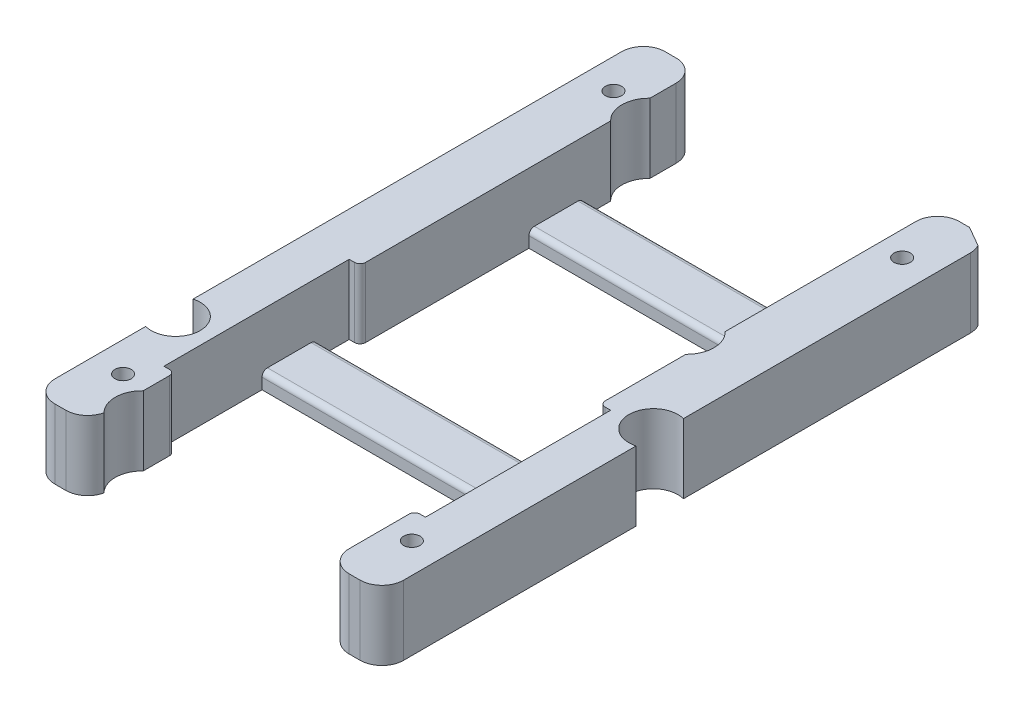
from build123d import *

# Parameters (mm, degrees)
SKETCH1_W             = 10
SKETCH1_H             = 112
BOSS_EXTRUDE1_DEPTH   = 12.75
BOSS_EXTRUDE1_2_DEPTH = 12.75
FILLET1_R             = 4
FILLET2_R             = 4
SKETCH2_R             = 1.5
SKETCH2_R_2           = 3
CUT_EXTRUDE1_DEPTH    = 13.75
SKETCH3_W             = 48
SKETCH3_H             = 34
CUT_EXTRUDE2_DEPTH    = 12.75
SKETCH4_R             = 5
SKETCH4_R_2           = 4.5
CUT_EXTRUDE3_DEPTH    = 13.75
SKETCH5_W             = 10
SKETCH5_H             = 3
BOSS_EXTRUDE2_DEPTH   = 44
BOSS_EXTRUDE3_REACH   = 58
SKETCH6_W             = 10
SKETCH6_H             = 3
FILLET3_R             = 1


with BuildPart() as part:
    # Sketch1 → Boss-Extrude1 (new body)
    with BuildSketch(Plane(origin=(0, 0, 0), x_dir=(1, 0, 0), z_dir=(0, 1, 0))):
        with Locations((-27, 56)):
            Rectangle(SKETCH1_W, SKETCH1_H)
    extrude(amount=BOSS_EXTRUDE1_DEPTH)

    # Fillet2
    fillet2_edges = [part.edges().sort_by_distance(p)[0] for p in [
        (-22, 6.375, -112),
        (-22, 6.375, 0),
        (-32, 6.375, 0),
        (-32, 6.375, -112),
    ]]
    fillet(fillet2_edges, radius=FILLET2_R)


with BuildPart() as body_2:
    # Sketch1 → Boss-Extrude1 2 (new body)
    with BuildSketch(Plane(origin=(0, 0, 0), x_dir=(1, 0, 0), z_dir=(0, 1, 0))):
        with Locations((27, 56)):
            Rectangle(SKETCH1_W, SKETCH1_H)
    extrude(amount=BOSS_EXTRUDE1_2_DEPTH)

    # Fillet1
    fillet1_edges = [body_2.edges().sort_by_distance(p)[0] for p in [
        (22, 6.375, 0),
        (22, 6.375, -112),
        (32, 6.375, -112),
        (32, 6.375, 0),
    ]]
    fillet(fillet1_edges, radius=FILLET1_R)


with BuildPart() as cut_extrude1_tool:
    # Sketch2 → Cut-Extrude1 (new body, through all)
    with BuildSketch(Plane(origin=(0, 12.75, 0), x_dir=(1, 0, 0), z_dir=(0, 1, 0))):
        with Locations((-26.5, 101)):
            Circle(SKETCH2_R)
        with Locations((26.5, 101)):
            Circle(SKETCH2_R)
        with Locations((26.5, 11)):
            Circle(SKETCH2_R)
        with Locations((-26.5, 11)):
            Circle(SKETCH2_R)
        with Locations((0, 38)):
            Circle(SKETCH2_R_2)
    extrude(amount=-CUT_EXTRUDE1_DEPTH)


with BuildPart() as part_1:
    add(part.part)

    # Cut-Extrude1: cut by cut_extrude1_tool
    add(cut_extrude1_tool.part, mode=Mode.SUBTRACT)


with BuildPart() as body_2_1:
    add(body_2.part)

    # Cut-Extrude1: cut by cut_extrude1_tool
    add(cut_extrude1_tool.part, mode=Mode.SUBTRACT)


with BuildPart() as cut_extrude2_tool:
    # Sketch3 → Cut-Extrude2 (new body)
    with BuildSketch(Plane(origin=(0, 12.75, 0), x_dir=(1, 0, 0), z_dir=(0, 1, 0))):
        with Locations((0, 33)):
            Rectangle(SKETCH3_W, SKETCH3_H)
    extrude(amount=-CUT_EXTRUDE2_DEPTH)


with BuildPart() as part_2:
    add(part_1.part)

    # Cut-Extrude2: cut by cut_extrude2_tool
    add(cut_extrude2_tool.part, mode=Mode.SUBTRACT)


with BuildPart() as body_2_2:
    add(body_2_1.part)

    # Cut-Extrude2: cut by cut_extrude2_tool
    add(cut_extrude2_tool.part, mode=Mode.SUBTRACT)


with BuildPart() as cut_extrude3_tool:
    # Sketch4 → Cut-Extrude3 (new body, through all)
    with BuildSketch(Plane.XZ):
        with Locations((18.538884711, -69.4)):
            Circle(SKETCH4_R)
        with Locations((-18.538884711, -99.6)):
            Circle(SKETCH4_R)
        with Locations((-18.538884711, -6.6)):
            Circle(SKETCH4_R)
        with Locations((30.838884711, -51)):
            Circle(SKETCH4_R_2)
        with Locations((-30.838884711, -25)):
            Circle(SKETCH4_R_2)
        with BuildLine():
            ThreePointArc((31.774007787, -109.75), (30.281326332, -111.686308388), (27.856664361, -112))
            add(Edge.make_bspline(
                [(31.774007787, -109.75), (30.468226645, -110.5), (29.162445503, -111.25), (27.856664361, -112)],
                knots=[0, 0, 0, 0, 1, 1, 1, 1], degree=3))
        make_face()
    extrude(amount=-CUT_EXTRUDE3_DEPTH)


with BuildPart() as part_3:
    add(part_2.part)

    # Cut-Extrude3: cut by cut_extrude3_tool
    add(cut_extrude3_tool.part, mode=Mode.SUBTRACT)



with BuildPart() as body_2_3:
    add(body_2_2.part)

    # Cut-Extrude3: cut by cut_extrude3_tool
    add(cut_extrude3_tool.part, mode=Mode.SUBTRACT)


with BuildPart() as part_4:
    add(part_3.part)

    add(body_2_3.part)  # Boss-Extrude2 merges body 2
    # Sketch5 → Boss-Extrude2 (add)
    with BuildSketch(Plane(origin=(-22, 0, 0), x_dir=(0, 0, -1), z_dir=(1, 0, 0))):
        with Locations((85.991581932, 1.5)):
            Rectangle(SKETCH5_W, SKETCH5_H)
    extrude(amount=BOSS_EXTRUDE2_DEPTH)

    # Sketch6 → Boss-Extrude3 (add, up to next)
    with BuildSketch(Plane(origin=(-24, 0, 0), x_dir=(0, 0, -1), z_dir=(1, 0, 0)), mode=Mode.PRIVATE) as boss_extrude3_sk1:
        with Locations((39, 1.5)):
            Rectangle(SKETCH6_W, SKETCH6_H)
    boss_extrude3_tool1 = extrude(boss_extrude3_sk1.sketch, amount=BOSS_EXTRUDE3_REACH, mode=Mode.PRIVATE) - part_4.part
    add(boss_extrude3_tool1.solids().sort_by_distance((-24, 1.5, -39))[0])

    # Fillet3
    fillet3_edges = [part_4.edges().sort_by_distance(p)[0] for p in [
        (0, 3, -90.991581932),
        (0, 3, -80.991581932),
        (-22, 6.375, -50),
        (-22, 6.375, -16),
        (0, 3, -34),
        (0, 3, -44),
        (22, 6.375, -16),
        (22, 6.375, -50),
    ]]
    fillet(fillet3_edges, radius=FILLET3_R)


solid = part_4.part
